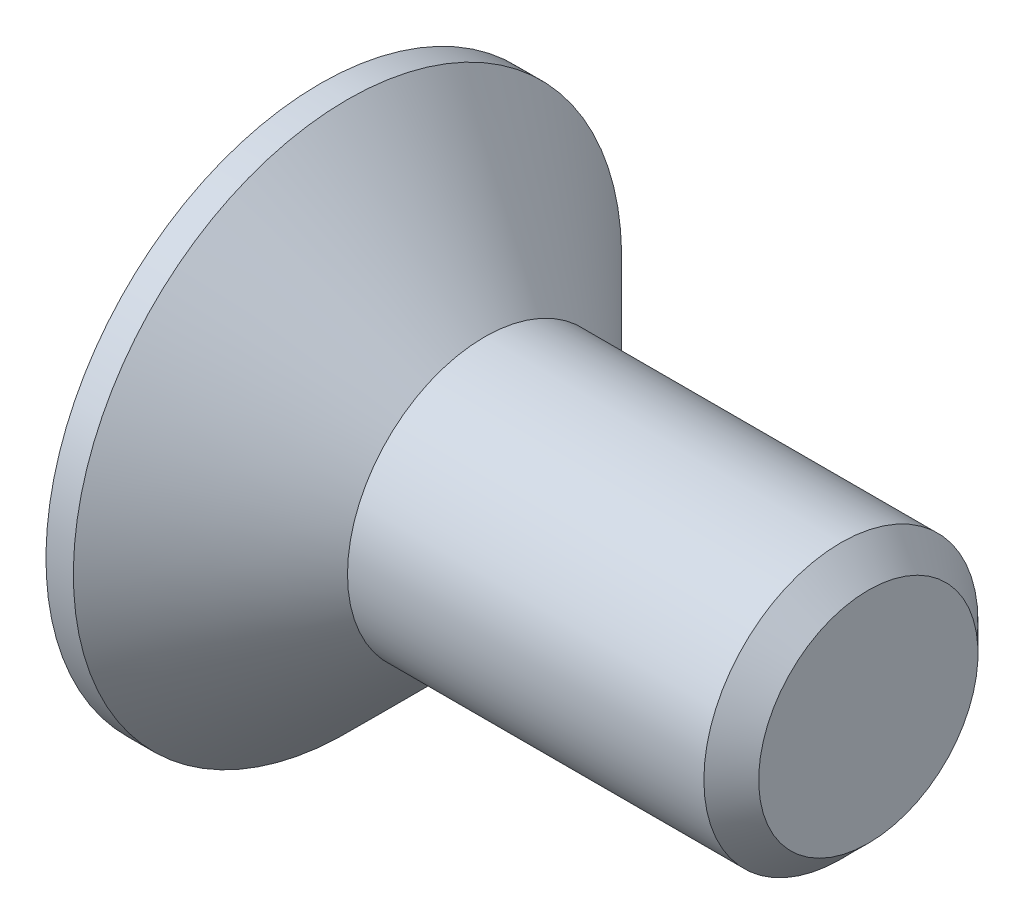
from build123d import *

# Parameters (mm, degrees)
CHANFREIN1_SIZE         = 0.5
ENL_V_MAT_EXTRU_1_DEPTH = 2.3


with BuildPart() as part:
    # Esquisse1 → Révolution1 (revolve)
    with BuildSketch(Plane.XY):
        Polygon((0, 0), (0, 5), (0.5, 5), (3, 2.5), (10, 2.5), (10, 0), align=None)
    revolve(axis=Axis((10, 0, 0), (-1, 0, 0)))

    # Chanfrein1
    chanfrein1_edges = [part.edges().sort_by_distance(p)[0] for p in [
        (10, -2.5, 0),
    ]]
    chamfer(chanfrein1_edges, length=CHANFREIN1_SIZE)

    # Esquisse2 → Enlèv. mat.-Extru.1 (cut)
    with BuildSketch(Plane.ZY):
        Polygon((0, 1.732050808), (-1.5, 0.866025404), (-1.5, -0.866025404), (0, -1.732050808), (1.5, -0.866025404), (1.5, 0.866025404), align=None)
    extrude(amount=-ENL_V_MAT_EXTRU_1_DEPTH, mode=Mode.SUBTRACT)


solid = part.part
